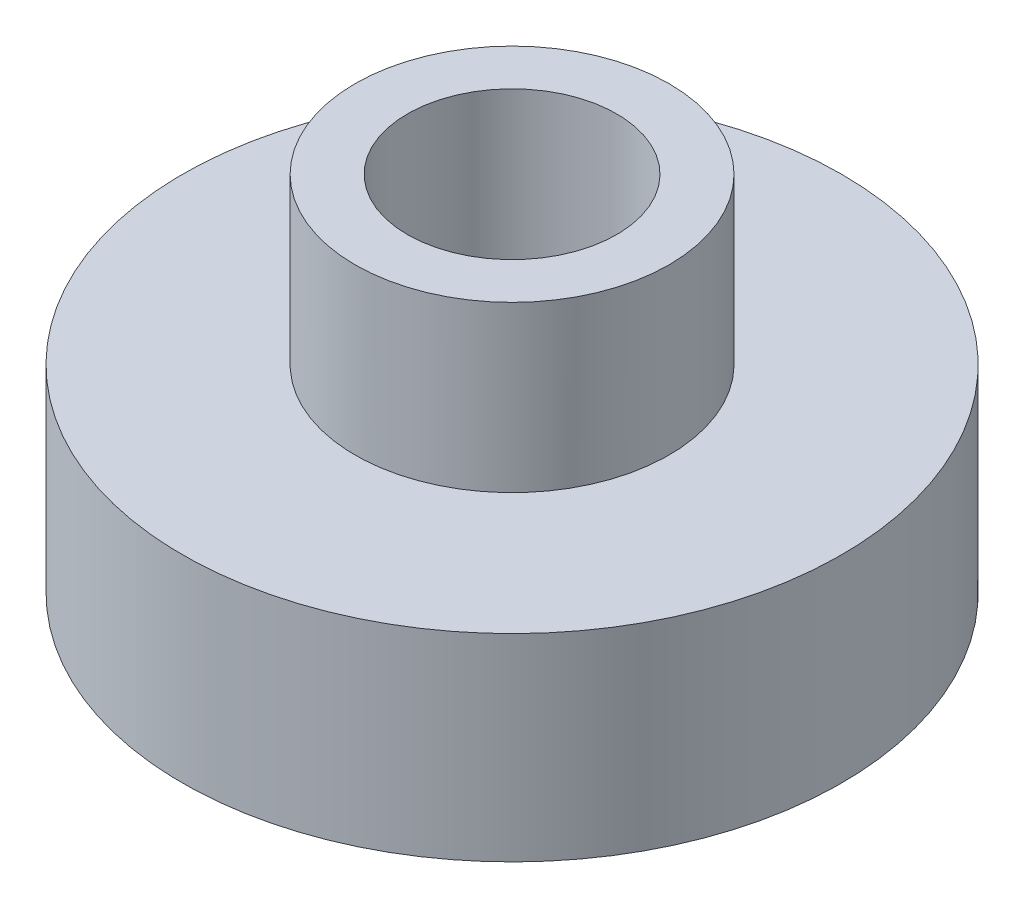
from build123d import *

# Parameters (mm, degrees)
SKETCH1_R           = 9.525
SKETCH1_R_2         = 6.35
BOSS_EXTRUDE1_DEPTH = 22
SKETCH2_R           = 20
SKETCH2_R_2         = 9.525
BOSS_EXTRUDE2_DEPTH = 12


with BuildPart() as part:
    # Sketch1 → Boss-Extrude1 (new body)
    with BuildSketch(Plane(origin=(0, 0, 0), x_dir=(1, 0, 0), z_dir=(0, 1, 0))):
        Circle(SKETCH1_R)
        Circle(SKETCH1_R_2, mode=Mode.SUBTRACT)
    extrude(amount=BOSS_EXTRUDE1_DEPTH)

    # Sketch2 → Boss-Extrude2 (add)
    with BuildSketch(Plane.XZ):
        Circle(SKETCH2_R)
        Circle(SKETCH2_R_2, mode=Mode.SUBTRACT)
    extrude(amount=-BOSS_EXTRUDE2_DEPTH)


solid = part.part
